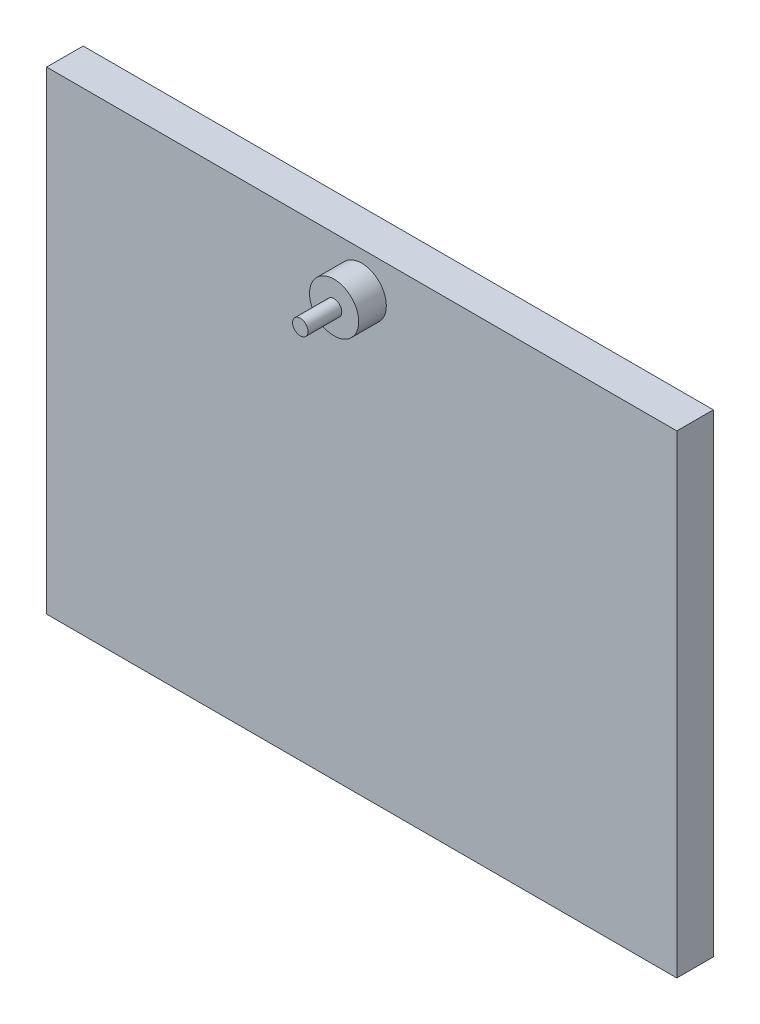
from build123d import *

# Parameters (mm, degrees)
SKETCH1_W           = 102.55
SKETCH1_H           = 77.1
BOSS_EXTRUDE1_DEPTH = 5.94
SKETCH2_R           = 4
BOSS_EXTRUDE2_DEPTH = 4.5
SKETCH3_R           = 1.25
BOSS_EXTRUDE3_DEPTH = 5.5
SKETCH5_R           = 4
BOSS_EXTRUDE4_DEPTH = 4.5
SKETCH6_R           = 1.25
BOSS_EXTRUDE5_DEPTH = 5.5


with BuildPart() as part:
    # Sketch1 → Boss-Extrude1 (new body)
    with BuildSketch(Plane.XY):
        Rectangle(SKETCH1_W, SKETCH1_H)
    extrude(amount=BOSS_EXTRUDE1_DEPTH)

    # Sketch2 → Boss-Extrude2 (add)
    with BuildSketch(Plane(origin=(0, 0, 0), x_dir=(-1, 0, 0), z_dir=(0, 0, -1))):
        with Locations((-30, -32.55)):
            Circle(SKETCH2_R)
        with Locations((-15, -32.55)):
            Circle(SKETCH2_R)
        with Locations((0, -32.55)):
            Circle(SKETCH2_R)
        with Locations((15, -32.55)):
            Circle(SKETCH2_R)
        with Locations((30, -32.55)):
            Circle(SKETCH2_R)
    extrude(amount=BOSS_EXTRUDE2_DEPTH)

    # Sketch3 → Boss-Extrude3 (add)
    with BuildSketch(Plane(origin=(0, 0, -4.5), x_dir=(-1, 0, 0), z_dir=(0, 0, -1))):
        with Locations((-30, -32.55)):
            Circle(SKETCH3_R)
        with Locations((-15, -32.55)):
            Circle(SKETCH3_R)
        with Locations((0, -32.55)):
            Circle(SKETCH3_R)
        with Locations((15, -32.55)):
            Circle(SKETCH3_R)
        with Locations((30, -32.55)):
            Circle(SKETCH3_R)
    extrude(amount=BOSS_EXTRUDE3_DEPTH)

    # Sketch5 → Boss-Extrude4 (add)
    with BuildSketch(Plane.XY.offset(5.94)):
        with Locations((0, 32.55)):
            Circle(SKETCH5_R)
    extrude(amount=BOSS_EXTRUDE4_DEPTH)

    # Sketch6 → Boss-Extrude5 (add)
    with BuildSketch(Plane.XY.offset(10.44)):
        with Locations((0, 32.55)):
            Circle(SKETCH6_R)
    extrude(amount=BOSS_EXTRUDE5_DEPTH)


solid = part.part
